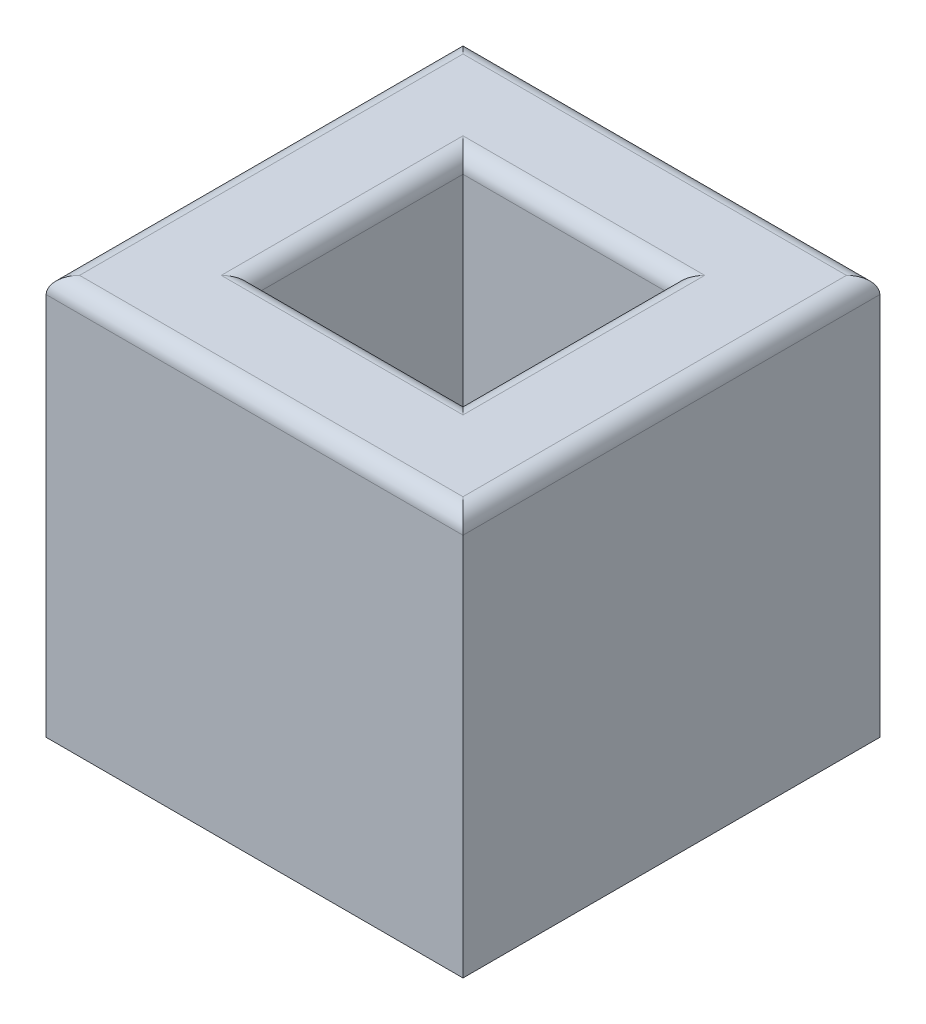
from build123d import *

# Parameters (mm, degrees)
SKETCH1_W           = 127
SKETCH1_H           = 127
BOSS_EXTRUDE1_DEPTH = 127
SKETCH2_W           = 63.5
SKETCH2_H           = 63.5
CUT_EXTRUDE1_DEPTH  = 128
CHAMFER1_SIZE       = 5.08
FILLET1_R           = 5.08


with BuildPart() as part:
    # Sketch1 → Boss-Extrude1 (new body)
    with BuildSketch(Plane(origin=(0, 0, 0), x_dir=(1, 0, 0), z_dir=(0, 1, 0))):
        Rectangle(SKETCH1_W, SKETCH1_H)
    extrude(amount=BOSS_EXTRUDE1_DEPTH)

    # Sketch2 → Cut-Extrude1 (cut, through all)
    with BuildSketch(Plane(origin=(0, 127, 0), x_dir=(1, 0, 0), z_dir=(0, 1, 0))):
        Rectangle(SKETCH2_W, SKETCH2_H)
    extrude(amount=-CUT_EXTRUDE1_DEPTH, mode=Mode.SUBTRACT)

    # Chamfer1
    chamfer1_edges = [part.edges().sort_by_distance(p)[0] for p in [
        (31.75, 0, 0),
        (0, 0, 31.75),
        (-31.75, 0, 0),
        (0, 0, -31.75),
        (0, 0, 63.5),
        (-63.5, 0, 0),
        (0, 0, -63.5),
        (63.5, 0, 0),
    ]]
    chamfer(chamfer1_edges, length=CHAMFER1_SIZE)

    # Fillet1
    fillet1_edges = [part.edges().sort_by_distance(p)[0] for p in [
        (-63.5, 127, 0),
        (0, 127, 63.5),
        (31.75, 127, 0),
        (0, 127, -31.75),
        (-31.75, 127, 0),
        (0, 127, 31.75),
        (63.5, 127, 0),
        (0, 127, -63.5),
    ]]
    fillet(fillet1_edges, radius=FILLET1_R)


solid = part.part
